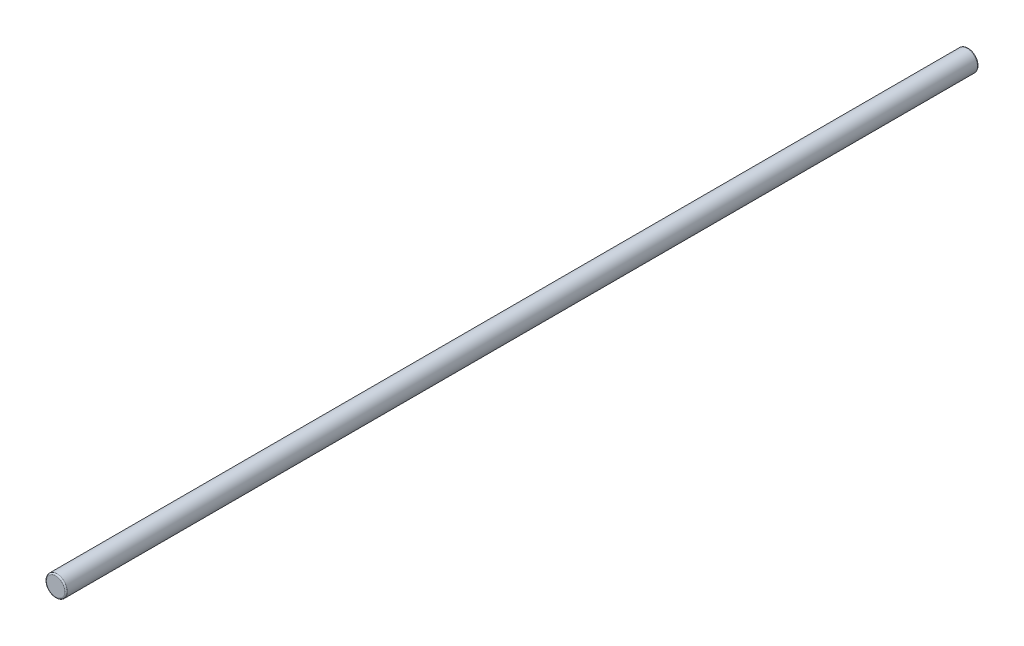
from build123d import *

# Parameters (mm, degrees)
ESQUISSE1_R        = 4
BOSS_EXTRU_1_DEPTH = 350
CONG_1_R           = 0.5


with BuildPart() as part:
    # Esquisse1 → Boss.-Extru.1 (new body)
    with BuildSketch(Plane.XY):
        Circle(ESQUISSE1_R)
    extrude(amount=BOSS_EXTRU_1_DEPTH)

    # Congé1
    cong_1_edges = [part.edges().sort_by_distance(p)[0] for p in [
        (-4, 0, 0),
        (-4, 0, 350),
    ]]
    fillet(cong_1_edges, radius=CONG_1_R)


solid = part.part
